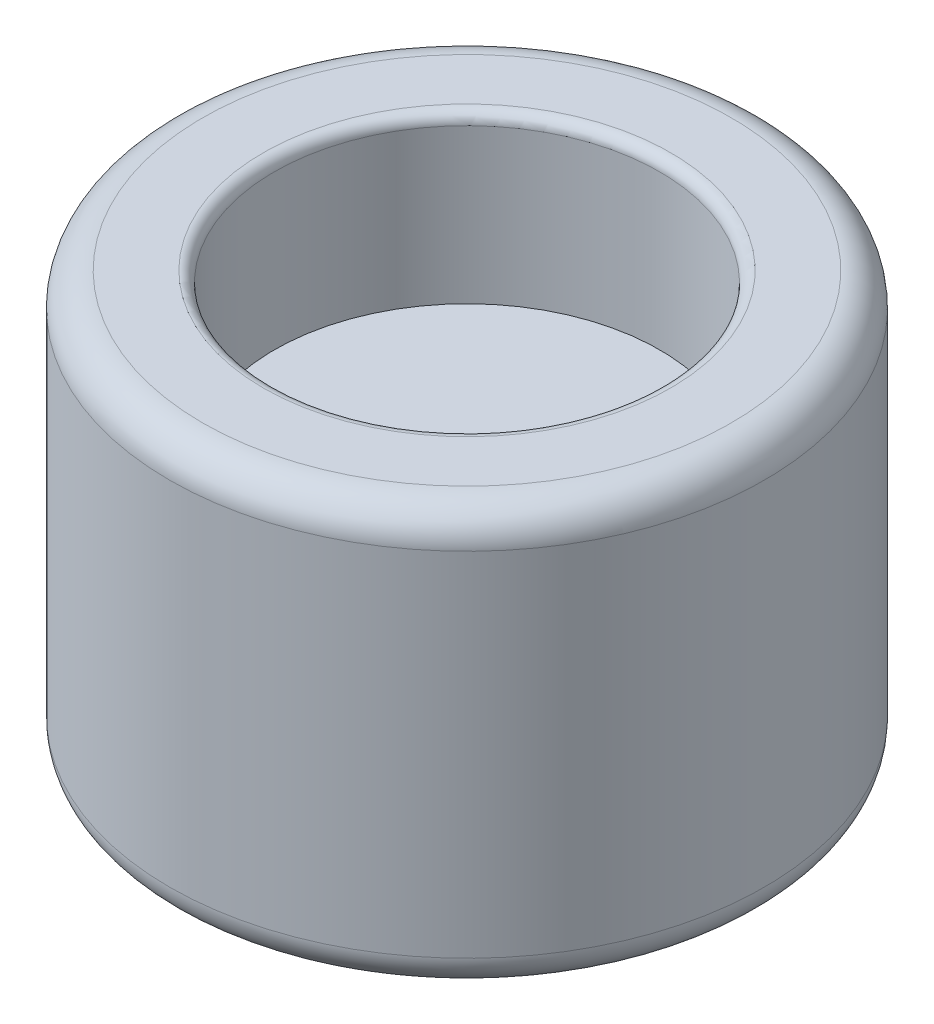
from build123d import *

# Parameters (mm, degrees)
ESQUISSE1_R             = 27
BOSS_EXTRU_1_DEPTH      = 38
CONG_1_R                = 3
CONG_2_R                = 3
ESQUISSE2_R             = 17.5
ENL_V_MAT_EXTRU_1_DEPTH = 15
ESQUISSE3_R             = 17.5
ENL_V_MAT_EXTRU_2_DEPTH = 15
ESQUISSE4_R             = 3
ENL_V_MAT_EXTRU_3_DEPTH = 15
CONG_3_R                = 1
CONG_4_R                = 1


with BuildPart() as part:
    # Esquisse1 → Boss.-Extru.1 (new body)
    with BuildSketch(Plane(origin=(0, 0, 0), x_dir=(1, 0, 0), z_dir=(0, 1, 0))):
        Circle(ESQUISSE1_R)
    extrude(amount=BOSS_EXTRU_1_DEPTH)

    # Congé1
    cong_1_edges = [part.edges().sort_by_distance(p)[0] for p in [
        (-27, 38, 0),
    ]]
    fillet(cong_1_edges, radius=CONG_1_R)

    # Congé2
    cong_2_edges = [part.edges().sort_by_distance(p)[0] for p in [
        (-27, 0, 0),
    ]]
    fillet(cong_2_edges, radius=CONG_2_R)

    # Esquisse2 → Enlèv. mat.-Extru.1 (cut)
    with BuildSketch(Plane.XZ):
        Circle(ESQUISSE2_R)
    extrude(amount=-ENL_V_MAT_EXTRU_1_DEPTH, mode=Mode.SUBTRACT)

    # Esquisse3 → Enlèv. mat.-Extru.2 (cut)
    with BuildSketch(Plane(origin=(0, 38, 0), x_dir=(1, 0, 0), z_dir=(0, 1, 0))):
        Circle(ESQUISSE3_R)
    extrude(amount=-ENL_V_MAT_EXTRU_2_DEPTH, mode=Mode.SUBTRACT)

    # Esquisse4 → Enlèv. mat.-Extru.3 (cut)
    with BuildSketch(Plane(origin=(0, 23, 0), x_dir=(1, 0, 0), z_dir=(0, 1, 0))):
        Circle(ESQUISSE4_R)
    extrude(amount=-ENL_V_MAT_EXTRU_3_DEPTH, mode=Mode.SUBTRACT)

    # Congé3
    cong_3_edges = [part.edges().sort_by_distance(p)[0] for p in [
        (-17.5, 38, 0),
    ]]
    fillet(cong_3_edges, radius=CONG_3_R)

    # Congé4
    cong_4_edges = [part.edges().sort_by_distance(p)[0] for p in [
        (-17.5, 0, 0),
    ]]
    fillet(cong_4_edges, radius=CONG_4_R)


solid = part.part
